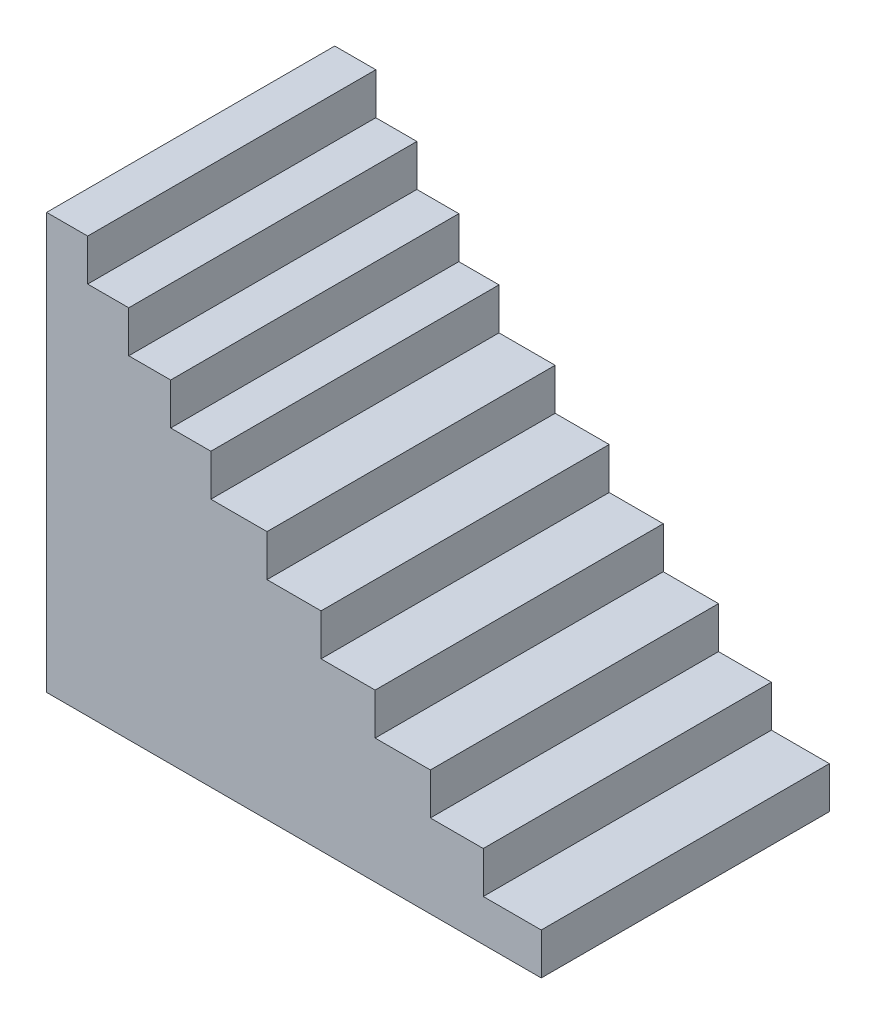
from build123d import *

# Parameters (mm, degrees)
CROQUIS1_W              = 128.409435803
CROQUIS1_H              = 130
CROQUIS1_W_2            = 1200
SALIENTE_EXTRUIR1_DEPTH = 901


with BuildPart() as part:
    # Croquis1 → Saliente-Extruir1 (new body)
    with BuildSketch(Plane.XY):
        with Locations((64.204717902, 975)):
            Rectangle(CROQUIS1_W, CROQUIS1_H)
        Polygon((0, 910), (0, 780), (256.818871606, 780), (256.818871606, 910), (128.409435803, 910), align=None)
        Polygon((0, 780), (0, 650), (387.93663619, 650), (387.93663619, 780), (256.818871606, 780), align=None)
        Polygon((0, 650), (0, 520), (513.637743212, 520), (513.637743212, 650), (387.93663619, 650), align=None)
        Polygon((0, 520), (0, 390), (689.163594473, 390), (689.163594473, 520), (513.637743212, 520), align=None)
        Polygon((0, 390), (0, 260), (858.219540448, 260), (858.219540448, 390), (689.163594473, 390), align=None)
        Polygon((0, 260), (0, 130), (1027.275486423, 130), (1027.275486423, 260), (858.219540448, 260), align=None)
        with Locations((600, 65)):
            Rectangle(CROQUIS1_W_2, CROQUIS1_H)
        Polygon((1200, 0), (0, 0), (0, -130), (1365.387378374, -130), (1365.387378374, 0), align=None)
        Polygon((1365.387378374, -130), (0, -130), (0, -260), (1546.738302238, -260), (1546.738302238, -130), align=None)
    extrude(amount=SALIENTE_EXTRUIR1_DEPTH)


solid = part.part
